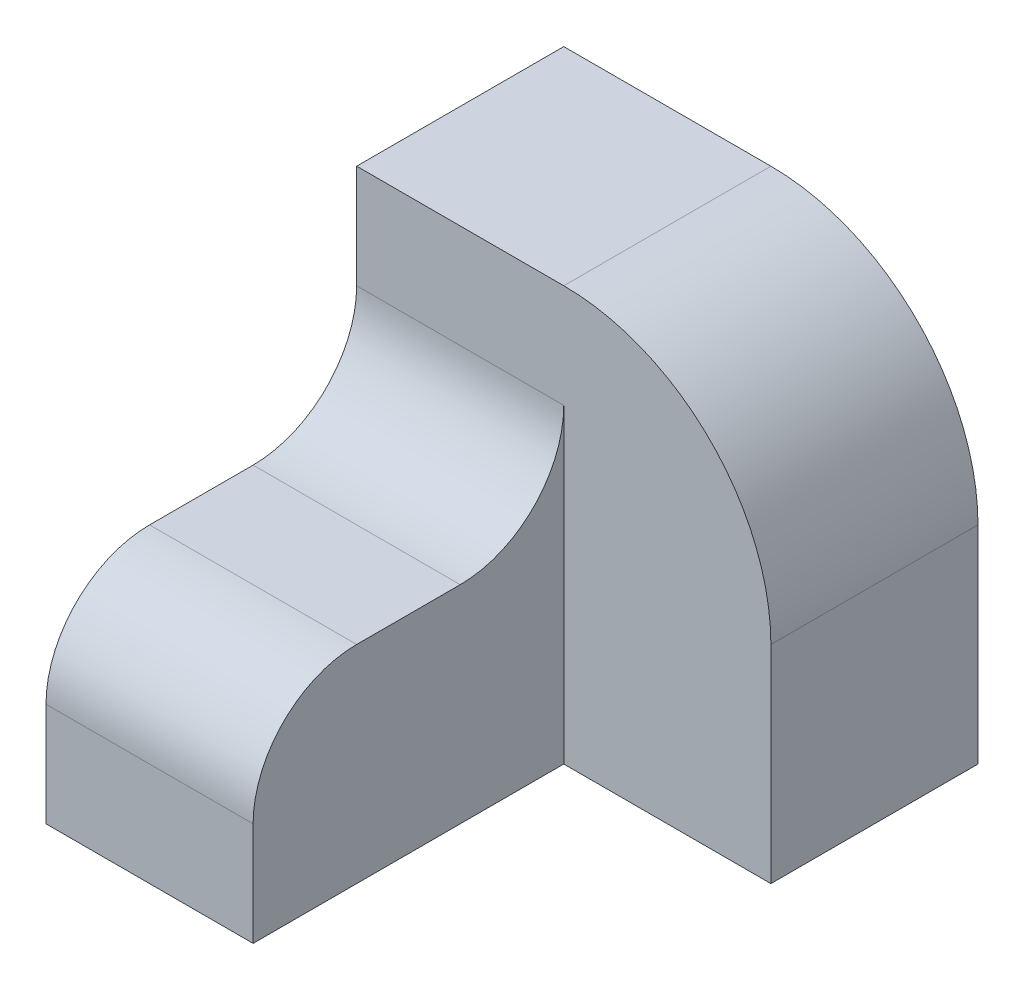
from build123d import *

# Parameters (mm, degrees)
SKETCH_1_W      = 10
SKETCH_1_H      = 15
EXTRUDE_1_DEPTH = 10
EXTRUDE_2_DEPTH = 20
FILLET_1_R      = 5
FILLET_2_R      = 10
SCALE_1_SCALE   = 0.2


with BuildPart() as part:
    # 草圖1 → 填料-伸長1 (new body)
    with BuildSketch(Plane(origin=(0, 0, 0), x_dir=(1, 0, 0), z_dir=(0, 1, 0))):
        with Locations((5, -7.5)):
            Rectangle(SKETCH_1_W, SKETCH_1_H)
    extrude(amount=EXTRUDE_1_DEPTH)

    # 草圖1<3> → 填料-伸長2 (add)
    with BuildSketch(Plane(origin=(0, 0, 0), x_dir=(1, 0, 0), z_dir=(0, 1, 0))):
        Polygon((0, 10), (0, 0), (10, 0), (20, 0), (20, 10), align=None)
    extrude(amount=EXTRUDE_2_DEPTH)

    # 圓角1
    fillet_1_edges = [part.edges().sort_by_distance(p)[0] for p in [
        (5, 10, 0),
        (5, 10, 15),
    ]]
    fillet(fillet_1_edges, radius=FILLET_1_R)

    # 圓角2
    fillet_2_edges = [part.edges().sort_by_distance(p)[0] for p in [
        (20, 20, -5),
    ]]
    fillet(fillet_2_edges, radius=FILLET_2_R)


with BuildPart() as part_1:
    # 縮放比例1: scaled about (8.26566204, 8.288335436, -1.58207755)
    add(part.part.scale(SCALE_1_SCALE).moved(Location((6.612529632, 6.630668349, -1.26566204))))


solid = part_1.part
